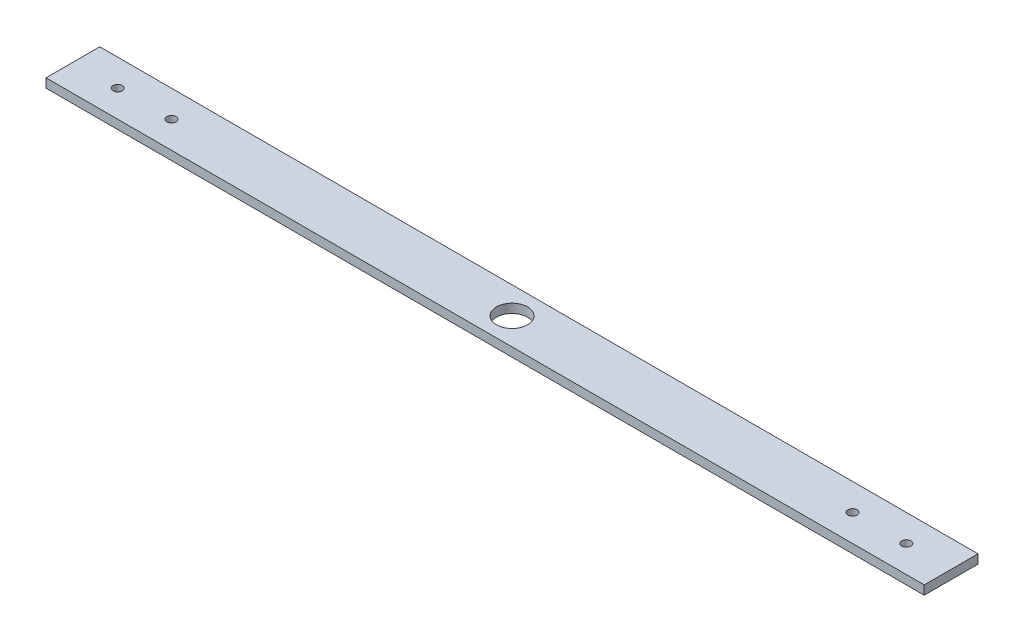
from build123d import *

# Parameters (mm, degrees)
SKETCH1_W                = 622.3
SKETCH1_H                = 38.1
BOSS_EXTRUDE1_DEPTH      = 6.35
SKETCH2_R                = 11
CUT_EXTRUDE1_DEPTH       = 1
CUT_EXTRUDE1_DEPTH_BACK  = 7.62
F_0_257_DIAMETER_HOLE2_D = 6.5278


with BuildPart() as part:
    # Sketch1 → Boss-Extrude1 (new body)
    with BuildSketch(Plane(origin=(0, 0, 0), x_dir=(1, 0, 0), z_dir=(0, 1, 0))):
        Rectangle(SKETCH1_W, SKETCH1_H)
    extrude(amount=BOSS_EXTRUDE1_DEPTH)

    # Sketch2 → Cut-Extrude1 (cut, two sides)
    with BuildSketch(Plane(origin=(0, 6.35, 0), x_dir=(1, 0, 0), z_dir=(0, 1, 0))) as cut_extrude1_sk:
        Circle(SKETCH2_R)
    extrude(amount=CUT_EXTRUDE1_DEPTH, mode=Mode.SUBTRACT)
    extrude(cut_extrude1_sk.sketch, amount=-CUT_EXTRUDE1_DEPTH_BACK, mode=Mode.SUBTRACT)

    # F (0.257) Diameter Hole2 (through all)
    with Locations(Plane(origin=(0, 6.35, 0), x_dir=(1, 0, 0), z_dir=(0, 1, 0))):
        with Locations((-279.4, 0), (-241.3, 0)):
            f_0_257_diameter_hole2 = Hole(F_0_257_DIAMETER_HOLE2_D / 2)

    # Mirror1: F (0.257) Diameter Hole2 across plane
    add(f_0_257_diameter_hole2.mirror(Plane(origin=(0, 0, 0), x_dir=(0, 0, 1), z_dir=(1, 0, 0))), mode=Mode.SUBTRACT)


solid = part.part
